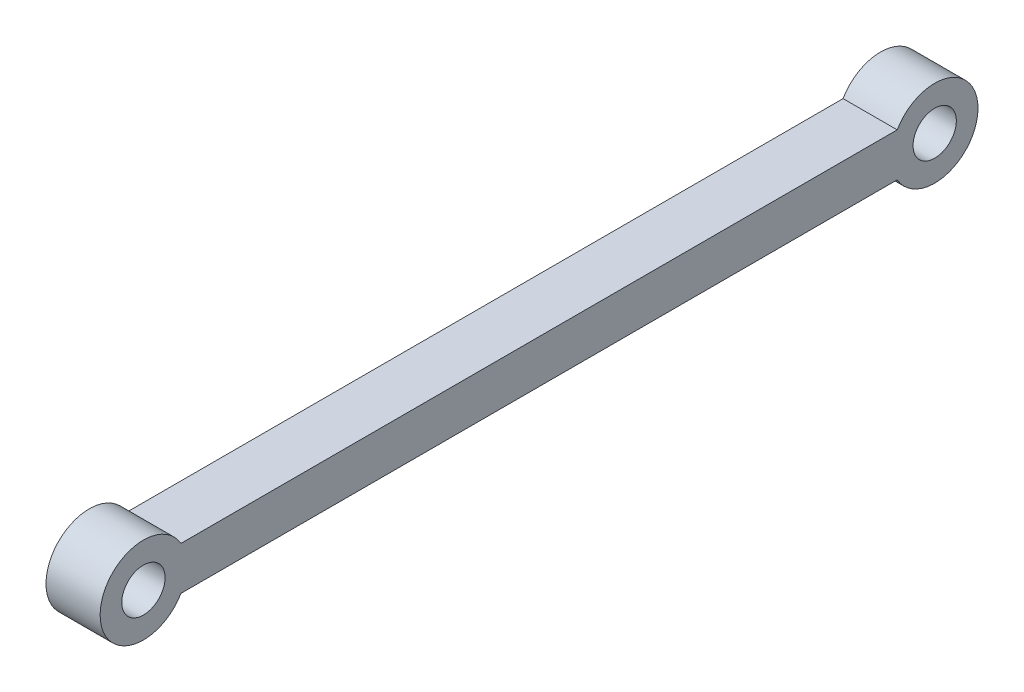
from build123d import *

# Parameters (mm, degrees)
SKETCH1_R           = 1
BOSS_EXTRUDE1_DEPTH = 1.25


with BuildPart() as part:
    # Sketch1 → Boss-Extrude1 (new body, symmetric)
    with BuildSketch(Plane(origin=(0, 0, 0), x_dir=(0, 0, -1), z_dir=(1, 0, 0))):
        with BuildLine():
            Line((-16.540999192, 1), (16.540999192, 1))
            ThreePointArc((16.540999192, 1), (20.27305, 0), (16.540999192, -1))
            Line((16.540999192, -1), (-16.540999192, -1))
            ThreePointArc((-16.540999192, -1), (-20.27305, 0), (-16.540999192, 1))
        make_face()
        with Locations((-18.27305, 0)):
            Circle(SKETCH1_R, mode=Mode.SUBTRACT)
        with Locations((18.27305, 0)):
            Circle(SKETCH1_R, mode=Mode.SUBTRACT)
    extrude(amount=BOSS_EXTRUDE1_DEPTH, both=True)


solid = part.part
